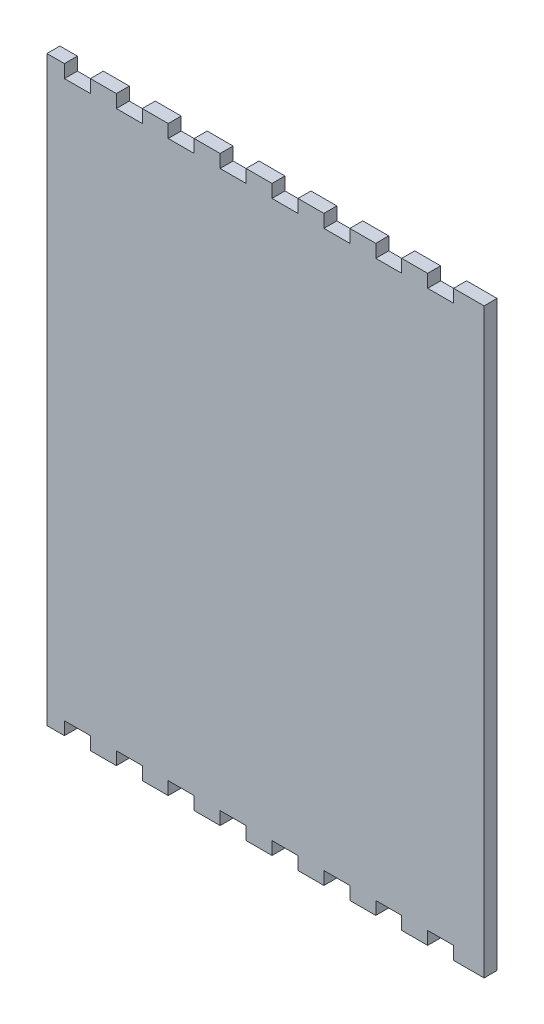
from build123d import *

# Parameters (mm, degrees)
BOSS_EXTRUDE1_DEPTH = 5.715


with BuildPart() as part:
    # Model → Boss-Extrude1 (new body)
    with BuildSketch(Plane.XY):
        Polygon((960.97344, 23.2006394), (968.68996, 23.2006394), (968.68996, 28.91536), (980.11996, 28.91536), (980.11996, 23.2006394), (991.54996, 23.2006394), (991.54996, 28.91536), (1002.97996, 28.91536), (1002.97996, 23.2006394), (1014.40996, 23.2006394), (1014.40996, 28.91536), (1025.83996, 28.91536), (1025.83996, 23.2006394), (1037.26996, 23.2006394), (1037.26996, 28.91536), (1048.69996, 28.91536), (1048.69996, 23.2006394), (1060.12996, 23.2006394), (1060.12996, 28.91536), (1071.55996, 28.91536), (1071.55996, 23.2006394), (1082.98996, 23.2006394), (1082.98996, 28.91536), (1094.41996, 28.91536), (1094.41996, 23.2006394), (1105.84996, 23.2006394), (1105.84996, 28.91536), (1117.27996, 28.91536), (1117.27996, 23.2006394), (1128.70996, 23.2006394), (1128.70996, 28.91536), (1140.13996, 28.91536), (1140.13996, 23.2006394), (1153.57148, 23.2006394), (1153.57148, 279.63114), (1140.13996, 279.63114), (1140.13996, 273.91614), (1128.70996, 273.91614), (1128.70996, 279.63114), (1117.27996, 279.63114), (1117.27996, 273.91614), (1105.84996, 273.91614), (1105.84996, 279.63114), (1094.41996, 279.63114), (1094.41996, 273.91614), (1082.98996, 273.91614), (1082.98996, 279.63114), (1071.55996, 279.63114), (1071.55996, 273.91614), (1060.12996, 273.91614), (1060.12996, 279.63114), (1048.69996, 279.63114), (1048.69996, 273.91614), (1037.26996, 273.91614), (1037.26996, 279.63114), (1025.83996, 279.63114), (1025.83996, 273.91614), (1014.40996, 273.91614), (1014.40996, 279.63114), (1002.97996, 279.63114), (1002.97996, 273.91614), (991.54996, 273.91614), (991.54996, 279.63114), (980.11996, 279.63114), (980.11996, 273.91614), (968.68996, 273.91614), (968.68996, 279.63114), (960.97344, 279.63114), align=None)
    extrude(amount=BOSS_EXTRUDE1_DEPTH)


solid = part.part
